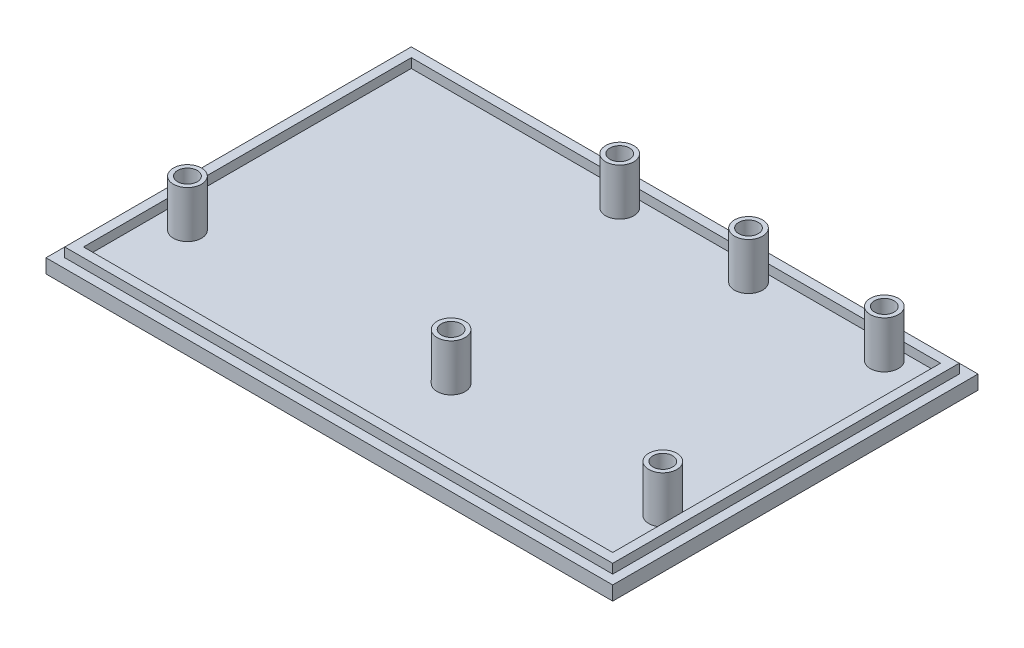
from build123d import *

# Parameters (mm, degrees)
SKETCH6_W            = 121
SKETCH6_H            = 78
BOSS_EXTRUDE9_DEPTH  = 3
SKETCH14_W           = 117
SKETCH14_H           = 74
SKETCH14_W_2         = 113
SKETCH14_H_2         = 70
BOSS_EXTRUDE11_DEPTH = 2
SKETCH16_R           = 3
SKETCH16_R_2         = 2.1
BOSS_EXTRUDE12_DEPTH = 10
SKETCH17_R           = 3
SKETCH17_R_2         = 2.1
BOSS_EXTRUDE13_DEPTH = 10
SKETCH18_R           = 3
SKETCH18_R_2         = 2.1
BOSS_EXTRUDE14_DEPTH = 10
SKETCH19_R           = 3
SKETCH19_R_2         = 2.1
BOSS_EXTRUDE15_DEPTH = 10
SKETCH20_R           = 3
SKETCH20_R_2         = 2.1
BOSS_EXTRUDE16_DEPTH = 10
SKETCH21_R           = 3
SKETCH21_R_2         = 2.1
BOSS_EXTRUDE17_DEPTH = 10
CUT_EXTRUDE2_DEPTH   = 1


with BuildPart() as part:
    # Sketch6 → Boss-Extrude9 (new body)
    with BuildSketch(Plane(origin=(0, 0, 0), x_dir=(1, 0, 0), z_dir=(0, 1, 0))):
        with Locations((60.5, 39)):
            Rectangle(SKETCH6_W, SKETCH6_H)
    extrude(amount=BOSS_EXTRUDE9_DEPTH)

    # Sketch14 → Boss-Extrude11 (add)
    with BuildSketch(Plane(origin=(0, 3, 0), x_dir=(1, 0, 0), z_dir=(0, 1, 0))):
        with Locations((60.5, 39)):
            Rectangle(SKETCH14_W, SKETCH14_H)
        with Locations((60.5, 39)):
            Rectangle(SKETCH14_W_2, SKETCH14_H_2, mode=Mode.SUBTRACT)
    extrude(amount=BOSS_EXTRUDE11_DEPTH)

    # Sketch16 → Boss-Extrude12 (add)
    with BuildSketch(Plane(origin=(0, 3, 0), x_dir=(1, 0, 0), z_dir=(0, 1, 0))):
        with Locations((52, 70.5)):
            Circle(SKETCH16_R)
        with Locations((52, 70.5)):
            Circle(SKETCH16_R_2, mode=Mode.SUBTRACT)
    extrude(amount=BOSS_EXTRUDE12_DEPTH)

    # Sketch17 → Boss-Extrude13 (add)
    with BuildSketch(Plane(origin=(0, 3, 0), x_dir=(1, 0, 0), z_dir=(0, 1, 0))):
        with Locations((108.5, 70.5)):
            Circle(SKETCH17_R)
        with Locations((108.5, 70.5)):
            Circle(SKETCH17_R_2, mode=Mode.SUBTRACT)
    extrude(amount=BOSS_EXTRUDE13_DEPTH)

    # Sketch18 → Boss-Extrude14 (add)
    with BuildSketch(Plane(origin=(0, 3, 0), x_dir=(1, 0, 0), z_dir=(0, 1, 0))):
        with Locations((79.5, 70.5)):
            Circle(SKETCH18_R)
        with Locations((79.5, 70.5)):
            Circle(SKETCH18_R_2, mode=Mode.SUBTRACT)
    extrude(amount=BOSS_EXTRUDE14_DEPTH)

    # Sketch19 → Boss-Extrude15 (add)
    with BuildSketch(Plane(origin=(0, 3, 0), x_dir=(1, 0, 0), z_dir=(0, 1, 0))):
        with Locations((10, 20.2)):
            Circle(SKETCH19_R)
        with Locations((10, 20.2)):
            Circle(SKETCH19_R_2, mode=Mode.SUBTRACT)
    extrude(amount=BOSS_EXTRUDE15_DEPTH)

    # Sketch20 → Boss-Extrude16 (add)
    with BuildSketch(Plane(origin=(0, 3, 0), x_dir=(1, 0, 0), z_dir=(0, 1, 0))):
        with Locations((113.5, 18.2)):
            Circle(SKETCH20_R)
        with Locations((113.5, 18.2)):
            Circle(SKETCH20_R_2, mode=Mode.SUBTRACT)
    extrude(amount=BOSS_EXTRUDE16_DEPTH)

    # Sketch21 → Boss-Extrude17 (add)
    with BuildSketch(Plane(origin=(0, 3, 0), x_dir=(1, 0, 0), z_dir=(0, 1, 0))):
        with Locations((66.5, 20)):
            Circle(SKETCH21_R)
        with Locations((66.5, 20)):
            Circle(SKETCH21_R_2, mode=Mode.SUBTRACT)
    extrude(amount=BOSS_EXTRUDE17_DEPTH)

    # Sketch22 → Cut-Extrude2 (cut)
    with BuildSketch(Plane(origin=(0, 0, 0), x_dir=(-1, 0, 0), z_dir=(0, -1, 0))):
        with BuildLine():
            Line((-59.348084392, 41.348070521), (-59.348084392, 41.022429495))
            Line((-59.348084392, 41.022429495), (-60.428042325, 41.022429495))
            Line((-60.428042325, 41.022429495), (-60.599131067, 40.187338349))
            add(Edge.make_bspline(
                [(-60.599131067, 40.187338349), (-60.565516095, 40.196618667), (-60.500392404, 40.214597816), (-60.404271673, 40.234560193), (-60.313020174, 40.246593846), (-60.253806088, 40.248236963), (-60.225152702, 40.249032059)],
                knots=[0, 0, 0, 0, 0.000104595, 0.000202637, 0.000294305, 0.000380252, 0.000380252, 0.000380252, 0.000380252], degree=3))
            add(Edge.make_bspline(
                [(-60.225152702, 40.249032059), (-60.189698166, 40.248264675), (-60.119985692, 40.246755805), (-60.017987504, 40.232267056), (-59.920621236, 40.209461562), (-59.828090515, 40.177602232), (-59.740224158, 40.136862688), (-59.657830585, 40.085972028), (-59.579673049, 40.026523934), (-59.507153696, 39.958175245), (-59.441363788, 39.882953493), (-59.383518926, 39.802074567), (-59.334385719, 39.716324473), (-59.294869892, 39.624883921), (-59.263315531, 39.528763832), (-59.242313364, 39.426952846), (-59.228328207, 39.320410623), (-59.226765757, 39.247562906), (-59.225969008, 39.210415273)],
                knots=[0, 0, 0, 0, 0.000106308, 0.000209029, 0.000308378, 0.000405929, 0.000502102, 0.000598312, 0.00069588, 0.000796219, 0.000896736, 0.000995218, 0.001094066, 0.001192613, 0.001293582, 0.001396995, 0.001504047, 0.001615439, 0.001615439, 0.001615439, 0.001615439], degree=3))
            add(Edge.make_bspline(
                [(-59.225969008, 39.210415273), (-59.226572326, 39.184541544), (-59.227770809, 39.133143748), (-59.233865528, 39.056812938), (-59.24560007, 38.982098082), (-59.261355077, 38.908989269), (-59.281804271, 38.83762491), (-59.306559341, 38.767800738), (-59.336854309, 38.699951345), (-59.370084199, 38.633434737), (-59.407500647, 38.569754662), (-59.449028293, 38.510201653), (-59.492902703, 38.453882341), (-59.540111674, 38.40140074), (-59.591094005, 38.353101717), (-59.645232261, 38.308698633), (-59.702094442, 38.267440569), (-59.762560269, 38.231002278), (-59.825282378, 38.197471596), (-59.891166547, 38.169963816), (-59.958713039, 38.145370694), (-60.028894034, 38.125767765), (-60.101550564, 38.110407519), (-60.176802396, 38.099974831), (-60.254254861, 38.092376206), (-60.306755765, 38.091900539), (-60.333275698, 38.091660265)],
                knots=[0, 0, 0, 0, 7.7636e-05, 0.000154223, 0.000229512, 0.000304362, 0.000378447, 0.000452077, 0.000526407, 0.000601214, 0.00067506, 0.000747747, 0.00081887, 0.000889121, 0.000959302, 0.001029336, 0.001099058, 0.00116985, 0.001240974, 0.00131221, 0.00138383, 0.001456517, 0.001530612, 0.001606437, 0.001684346, 0.001763871, 0.001763871, 0.001763871, 0.001763871], degree=3))
            add(Edge.make_bspline(
                [(-60.333275698, 38.091660265), (-60.364911562, 38.092286953), (-60.427151387, 38.093519889), (-60.518337902, 38.106418087), (-60.606071865, 38.124891068), (-60.689647029, 38.152682541), (-60.769812389, 38.187505301), (-60.845488712, 38.2315164), (-60.918609666, 38.281390301), (-60.986202728, 38.34024605), (-61.048937202, 38.404576704), (-61.105095249, 38.474388279), (-61.15510928, 38.548528558), (-61.198178379, 38.627357598), (-61.23491587, 38.710668266), (-61.263776609, 38.798772702), (-61.287070545, 38.891210563), (-61.296925219, 38.954849819), (-61.301930546, 38.987173085)],
                knots=[0, 0, 0, 0, 9.4843e-05, 0.000186593, 0.000275792, 0.000363484, 0.000450342, 0.000537514, 0.000625728, 0.000715478, 0.000805885, 0.000894984, 0.00098389, 0.001073836, 0.001164117, 0.001256635, 0.001351658, 0.001449737, 0.001449737, 0.001449737, 0.001449737], degree=3))
            Line((-61.301930546, 38.987173085), (-61.016994649, 38.987173085))
            add(Edge.make_bspline(
                [(-61.016994649, 38.987173085), (-61.009983743, 38.956895875), (-60.996508393, 38.898701395), (-60.966930321, 38.816939392), (-60.930766277, 38.744078382), (-60.887763761, 38.679154546), (-60.836464805, 38.62254067), (-60.777927394, 38.57208805), (-60.712297674, 38.526572039), (-60.63936953, 38.488632815), (-60.562431951, 38.45627616), (-60.48190741, 38.43472998), (-60.399988467, 38.419579884), (-60.34458166, 38.418063358), (-60.31673924, 38.41730129)],
                knots=[0, 0, 0, 0, 9.3172e-05, 0.000179081, 0.000260145, 0.000336703, 0.000411917, 0.000488562, 0.000568128, 0.000650923, 0.00073478, 0.000817953, 0.000900557, 0.000983994, 0.000983994, 0.000983994, 0.000983994], degree=3))
            add(Edge.make_bspline(
                [(-60.31673924, 38.41730129), (-60.289562651, 38.418045853), (-60.236051725, 38.419511903), (-60.157301396, 38.430795864), (-60.081271146, 38.448174518), (-60.008711186, 38.474182172), (-59.93835179, 38.50579131), (-59.871972727, 38.546354271), (-59.807653688, 38.59303586), (-59.747393881, 38.646517945), (-59.692203809, 38.70545474), (-59.643439328, 38.768480661), (-59.602820271, 38.835715229), (-59.568590044, 38.905994446), (-59.542597408, 38.980088566), (-59.524054518, 39.057650346), (-59.513166029, 39.138871364), (-59.511668173, 39.194269952), (-59.510904905, 39.222499607)],
                knots=[0, 0, 0, 0, 8.15e-05, 0.000160473, 0.000238226, 0.000315066, 0.000391338, 0.000469218, 0.000547964, 0.000629516, 0.000710512, 0.000789892, 0.000868102, 0.000945761, 0.001024012, 0.00110315, 0.001184644, 0.001269321, 0.001269321, 0.001269321, 0.001269321], degree=3))
            add(Edge.make_bspline(
                [(-59.510904905, 39.222499607), (-59.51150224, 39.247968325), (-59.512671438, 39.297819716), (-59.52222417, 39.370753282), (-59.53884028, 39.439762399), (-59.561903372, 39.505180311), (-59.591185496, 39.567068719), (-59.626968937, 39.625491495), (-59.669925234, 39.679678615), (-59.718994304, 39.729655432), (-59.772749813, 39.775778997), (-59.832116636, 39.815098275), (-59.895852427, 39.848176258), (-59.963189278, 39.876722228), (-60.035728864, 39.897224333), (-60.112034667, 39.912616629), (-60.19293068, 39.921520565), (-60.248239805, 39.922755992), (-60.276670129, 39.923391034)],
                knots=[0, 0, 0, 0, 7.6388e-05, 0.000149519, 0.000220172, 0.000288967, 0.000357247, 0.000425206, 0.000494043, 0.000564207, 0.000635056, 0.000706145, 0.000777268, 0.000850264, 0.000925136, 0.001002969, 0.001083601, 0.001168886, 0.001168886, 0.001168886, 0.001168886], degree=3))
            add(Edge.make_bspline(
                [(-60.276670129, 39.923391034), (-60.301279943, 39.922864355), (-60.352092966, 39.921776896), (-60.430037244, 39.913770002), (-60.511944736, 39.900852928), (-60.597501457, 39.883085404), (-60.686964346, 39.859834355), (-60.78014461, 39.831971916), (-60.877238166, 39.798659817), (-60.942659245, 39.773502737), (-60.97628952, 39.760570521)],
                knots=[0, 0, 0, 0, 7.3822e-05, 0.000152423, 0.000234822, 0.000322511, 0.00041445, 0.000512043, 0.000614219, 0.000722306, 0.000722306, 0.000722306, 0.000722306], degree=3))
            Line((-60.97628952, 39.760570521), (-60.650648495, 41.348070521))
            Line((-60.650648495, 41.348070521), (-59.348084392, 41.348070521))
        make_face()
        Polygon((-57.167179945, 41.429480777), (-57.109302341, 41.429480777), (-57.109302341, 39.231403854), (-56.742956187, 39.231403854), (-56.742956187, 38.905762829), (-57.109302341, 38.905762829), (-57.109302341, 38.173070521), (-57.394238238, 38.173070521), (-57.394238238, 38.905762829), (-58.900327982, 38.905762829), align=None)
        Polygon((-57.394238238, 39.231403854), (-57.394238238, 40.610290072), (-58.340632469, 39.231403854), align=None, mode=Mode.SUBTRACT)
    extrude(amount=-CUT_EXTRUDE2_DEPTH, mode=Mode.SUBTRACT)


solid = part.part
